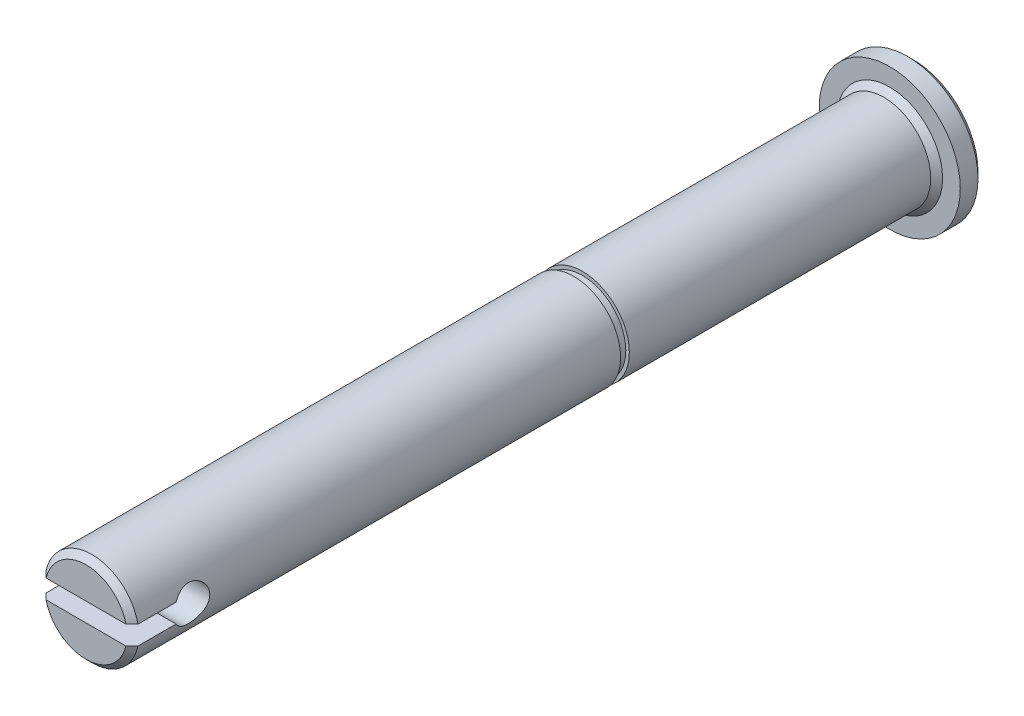
from build123d import *

# Parameters (mm, degrees)
EXTRUDE1_DEPTH      = 6.96875
EXTRUDE1_DEPTH_BACK = 6.96875
CHAMFER1_SIZE       = 0.5


with BuildPart() as part:
    # Sketch1 → Revolve1 (revolve)
    with BuildSketch(Plane(origin=(0, 0, 0), x_dir=(0, 0, -1), z_dir=(1, 0, 0))):
        Polygon((0, 3.96875), (-26, 3.96875), (-26, 3.9375), (-26, 3.668), (-26.7366, 3.668), (-26.7366, 3.96875), (-68, 3.96875), (-68, 0), (2, 0), (2, 5.96875), (0, 5.96875), align=None)
    revolve(axis=Axis((0, 0, 100.107110912), (0, 0, -1)))

    # Sketch2 → Extrude1 (cut, two sides)
    with BuildSketch(Plane(origin=(0, 0, 0), x_dir=(0, 0, -1), z_dir=(1, 0, 0))) as extrude1_sk:
        with BuildLine():
            Line((-69.561526288, 0.8), (-64.268857754, 0.8))
            ThreePointArc((-64.268857754, 0.8), (-61.5, 0), (-64.268857754, -0.8))
            Line((-64.268857754, -0.8), (-69.561526288, -0.8))
            Line((-69.561526288, -0.8), (-69.561526288, 0.8))
        make_face()
    extrude(amount=EXTRUDE1_DEPTH, mode=Mode.SUBTRACT)
    extrude(extrude1_sk.sketch, amount=-EXTRUDE1_DEPTH_BACK, mode=Mode.SUBTRACT)

    # Chamfer1
    chamfer1_edges = [part.edges().sort_by_distance(p)[0] for p in [
        (2.507586146, 3.076197049, 68),
        (0, -5.96875, -2),
        (0, -3.96875, 68),
        (0, -3.96875, 0),
    ]]
    chamfer(chamfer1_edges, length=CHAMFER1_SIZE)


solid = part.part
